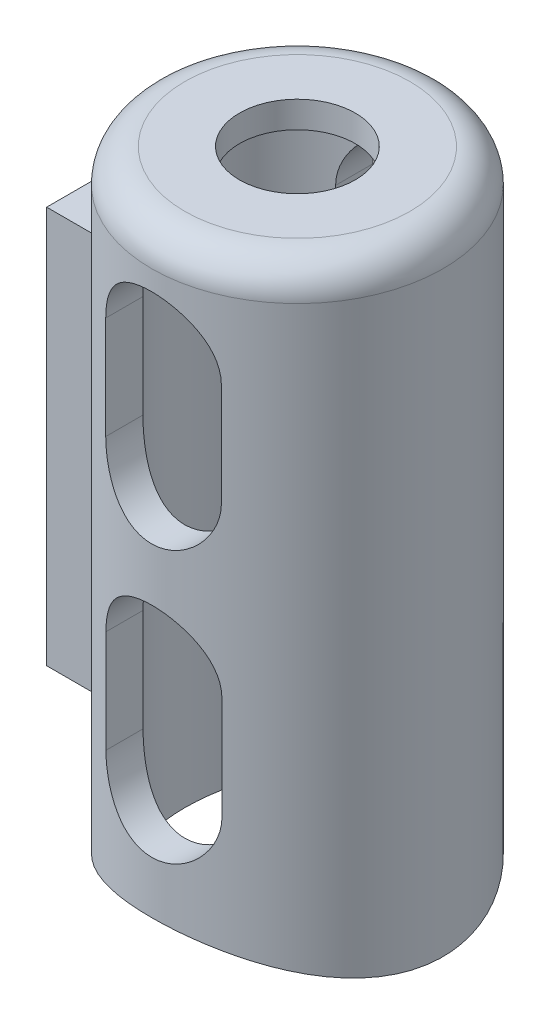
from build123d import *

# Parameters (mm, degrees)
SKETCH1_R                = 11.176
SKETCH1_R_2              = 8.636
BOSS_EXTRUDE1_DEPTH      = 45.72
BOSS_EXTRUDE1_DEPTH_BACK = 2.54
SKETCH2_R                = 10.668
BOSS_EXTRUDE2_DEPTH      = 2.032
CUT_EXTRUDE1_DEPTH       = 49.374831803
CUT_EXTRUDE1_DEPTH_BACK  = 49.374831803
CUT_EXTRUDE2_REACH       = 52.782
SKETCH4_R                = 4.445
SKETCH5_W                = 12.065
SKETCH5_H                = 30.48
BOSS_EXTRUDE3_DEPTH      = 2.032
BOSS_EXTRUDE3_DEPTH_BACK = 2.54
SKETCH6_R                = 3.683
CUT_EXTRUDE3_DEPTH       = 2.286
CUT_EXTRUDE4_DEPTH       = 54.007554634
FILLET1_R                = 2.54


with BuildPart() as part:
    # Sketch1 → Boss-Extrude1 (new, two sides)
    with BuildSketch(Plane(origin=(0, 0, 0), x_dir=(1, 0, 0), z_dir=(0, 1, 0))) as boss_extrude1_sk:
        with Locations(Location((0, 0, 0), (0, 0, 270))):
            Circle(SKETCH1_R)
        with Locations(Location((0, 0, 0), (0, 0, 270))):
            Circle(SKETCH1_R_2, mode=Mode.SUBTRACT)
    extrude(amount=BOSS_EXTRUDE1_DEPTH)
    extrude(boss_extrude1_sk.sketch, amount=-BOSS_EXTRUDE1_DEPTH_BACK)

    # Sketch2 → Boss-Extrude2 (add)
    with BuildSketch(Plane(origin=(0, 45.72, 0), x_dir=(1, 0, 0), z_dir=(0, 1, 0))):
        Circle(SKETCH2_R)
    extrude(amount=-BOSS_EXTRUDE2_DEPTH)

    # Sketch3 → Cut-Extrude1 (cut, two sides)
    with BuildSketch(Plane.XY) as cut_extrude1_sk:
        with BuildLine():
            Line((4.429766635, 37.211), (4.429766635, 29.336942899))
            ThreePointArc((4.429766635, 29.336942899), (-0.015233365, 24.891942899), (-4.460233365, 29.336942899))
            Line((-4.460233365, 29.336942899), (-4.460233365, 37.211))
            ThreePointArc((-4.460233365, 37.211), (-0.015233365, 41.656), (4.429766635, 37.211))
        make_face()
        with BuildLine():
            Line((-4.429766635, 8.509), (-4.429766635, 16.383057101))
            ThreePointArc((-4.429766635, 16.383057101), (0.015233365, 20.828057101), (4.460233365, 16.383057101))
            Line((4.460233365, 16.383057101), (4.460233365, 8.509))
            ThreePointArc((4.460233365, 8.509), (0.015233365, 4.064), (-4.429766635, 8.509))
        make_face()
    extrude(amount=CUT_EXTRUDE1_DEPTH, mode=Mode.SUBTRACT)
    extrude(cut_extrude1_sk.sketch, amount=-CUT_EXTRUDE1_DEPTH_BACK, mode=Mode.SUBTRACT)

    # Sketch4 → Cut-Extrude2 (cut, up to next)
    with BuildSketch(Plane(origin=(0, 45.72, 0), x_dir=(1, 0, 0), z_dir=(0, 1, 0)), mode=Mode.PRIVATE) as cut_extrude2_sk1:
        with Locations(Location((0, 0, 0), (0, 0, 270))):
            Circle(SKETCH4_R)
    cut_extrude2_tool1 = extrude(cut_extrude2_sk1.sketch, amount=-CUT_EXTRUDE2_REACH, mode=Mode.PRIVATE) & part.part
    add(cut_extrude2_tool1.solids().sort_by_distance((0, 45.72, 0))[0], mode=Mode.SUBTRACT)

    # Sketch5 → Boss-Extrude3 (add, two sides)
    with BuildSketch(Plane(origin=(-10.668, 0, 0), x_dir=(0, 0, -1), z_dir=(1, 0, 0))) as boss_extrude3_sk:
        with Locations((0, 22.86)):
            Rectangle(SKETCH5_W, SKETCH5_H)
    extrude(amount=BOSS_EXTRUDE3_DEPTH)
    extrude(boss_extrude3_sk.sketch, amount=-BOSS_EXTRUDE3_DEPTH_BACK)

    # Sketch6 → Cut-Extrude3 (cut)
    with BuildSketch(Plane.ZY.offset(13.208)):
        with Locations((0, 22.86)):
            Circle(SKETCH6_R)
    extrude(amount=-CUT_EXTRUDE3_DEPTH, mode=Mode.SUBTRACT)

    # Sketch8 → Cut-Extrude4 (cut, through all)
    with BuildSketch(Plane.ZY.offset(13.208)):
        with BuildLine():
            Line((-13.894688237, -6.768770079), (13.894688237, -6.768770079))
            Line((13.894688237, -6.768770079), (13.894688237, 1.597412227))
            ThreePointArc((13.894688237, 1.597412227), (0, -2.54), (-13.894688237, 1.597412227))
            Line((-13.894688237, 1.597412227), (-13.894688237, -6.768770079))
        make_face()
    extrude(amount=-CUT_EXTRUDE4_DEPTH, mode=Mode.SUBTRACT)

    # Fillet1
    fillet1_edges = [part.edges().sort_by_distance(p)[0] for p in [
        (0, 45.72, -11.176),
    ]]
    fillet(fillet1_edges, radius=FILLET1_R)


solid = part.part
